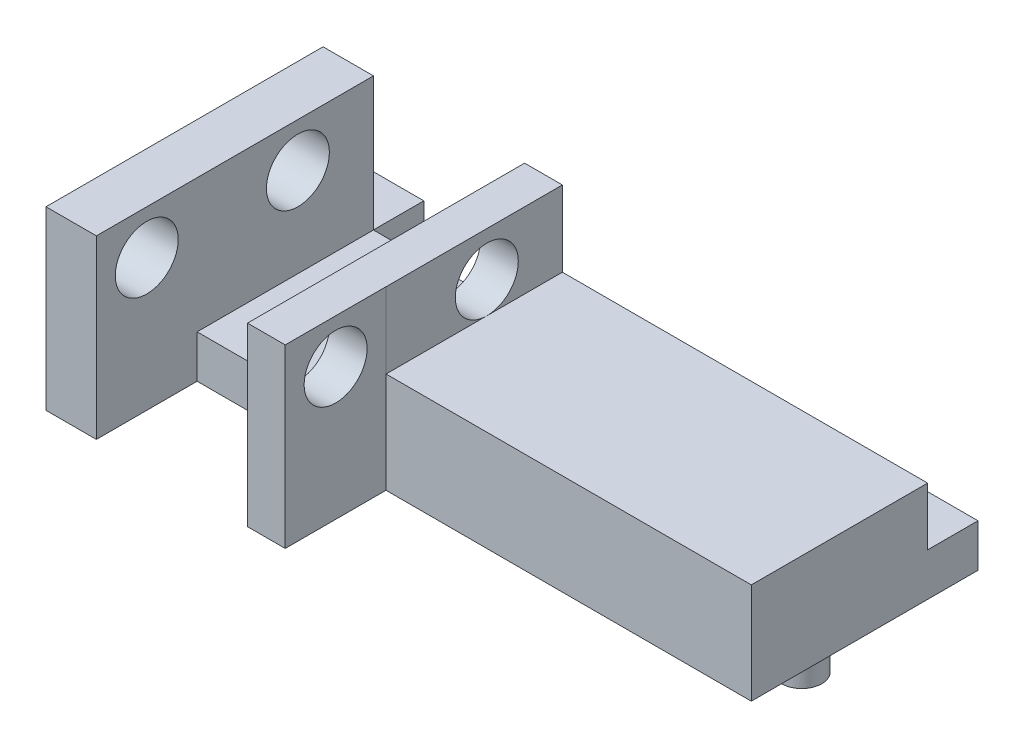
from build123d import *

# Parameters (mm, degrees)
BOSS_EXTRUDE1_DEPTH = 3
SKETCH3_W           = 24
SKETCH3_H           = 4
BOSS_EXTRUDE2_DEPTH = 4
SKETCH6_W           = 24
SKETCH6_H           = 4
BOSS_EXTRUDE4_DEPTH = 3
CUT_EXTRUDE1_DEPTH  = 2.3
SKETCH9_W           = 2
SKETCH9_H           = 7
SKETCH9_W_2         = 1.5
BOSS_EXTRUDE5_DEPTH = 3
SKETCH11_W          = 2
SKETCH11_H          = 7
SKETCH11_W_2        = 1.497470588
BOSS_EXTRUDE6_DEPTH = 4
SKETCH10_R          = 1.25
CUT_EXTRUDE2_DEPTH  = 10.5
BOSS_EXTRUDE7_DEPTH = 2


with BuildPart() as part:
    # Sketch1 → Boss-Extrude1 (new body)
    with BuildSketch(Plane(origin=(0, 0, 0), x_dir=(1, 0, 0), z_dir=(0, 1, 0))):
        with BuildLine():
            ThreePointArc((-17.3, 2), (-18.5, 3.2), (-19.7, 2))
            Line((-19.7, 2), (-17.3, 2))
        make_face()
        with BuildLine():
            Line((-17.3, 2), (-19.7, 2))
            ThreePointArc((-19.7, 2), (-18.5, 0.8), (-17.3, 2))
        make_face()
        with BuildLine():
            Line((-23, 2.8), (-23, 2))
            Line((-23, 2), (-23, 1.2))
            ThreePointArc((-23, 1.2), (-22.434314575, 1.434314575), (-22.2, 2))
            ThreePointArc((-22.2, 2), (-22.434314575, 2.565685425), (-23, 2.8))
        make_face()
        with BuildLine():
            Line((-23, 1.2), (-23, 2))
            Line((-23, 2), (-23.8, 2))
            ThreePointArc((-23.8, 2), (-23.565685425, 1.434314575), (-23, 1.2))
        make_face()
        with BuildLine():
            Line((-23.8, 2), (-23, 2))
            Line((-23, 2), (-23, 2.8))
            ThreePointArc((-23, 2.8), (-23.565685425, 2.565685425), (-23.8, 2))
        make_face()
        with BuildLine():
            ThreePointArc((-13.2, 2), (-14, 2.8), (-14.8, 2))
            Line((-14.8, 2), (-13.2, 2))
        make_face()
        with BuildLine():
            Line((-13.2, 2), (-14.8, 2))
            ThreePointArc((-14.8, 2), (-14, 1.2), (-13.2, 2))
        make_face()
        with BuildLine():
            ThreePointArc((-3.2, 2), (-4, 2.8), (-4.8, 2))
            Line((-4.8, 2), (-3.2, 2))
        make_face()
        with BuildLine():
            Line((-3.2, 2), (-4.8, 2))
            ThreePointArc((-4.8, 2), (-4, 1.2), (-3.2, 2))
        make_face()
    extrude(amount=-BOSS_EXTRUDE1_DEPTH)

    # Sketch3 → Boss-Extrude2 (add)
    with BuildSketch(Plane(origin=(0, 0, 0), x_dir=(1, 0, 0), z_dir=(0, 1, 0))):
        with Locations((-13, 2)):
            Rectangle(SKETCH3_W, SKETCH3_H)
    extrude(amount=BOSS_EXTRUDE2_DEPTH)

    # Sketch6 → Boss-Extrude4 (add)
    with BuildSketch(Plane.XY):
        with Locations((-13, 2)):
            Rectangle(SKETCH6_W, SKETCH6_H)
    extrude(amount=BOSS_EXTRUDE4_DEPTH)

    # Sketch7 → Cut-Extrude1 (cut)
    with BuildSketch(Plane(origin=(0, 4, 0), x_dir=(1, 0, 0), z_dir=(0, 1, 0))):
        Polygon((-23, 0.5), (-23, -3), (-17, -3), (-17, 4), (-23, 4), align=None)
    extrude(amount=-CUT_EXTRUDE1_DEPTH, mode=Mode.SUBTRACT)

    # Sketch9 → Boss-Extrude5 (add)
    with BuildSketch(Plane(origin=(0, 4, 0), x_dir=(1, 0, 0), z_dir=(0, 1, 0))):
        with Locations((-24, 0.5)):
            Rectangle(SKETCH9_W, SKETCH9_H)
        with Locations((-16.25, 0.5)):
            Rectangle(SKETCH9_W_2, SKETCH9_H)
    extrude(amount=BOSS_EXTRUDE5_DEPTH)

    # Sketch11 → Boss-Extrude6 (add)
    with BuildSketch(Plane.XY.offset(3)):
        with Locations((-24, 3.5)):
            Rectangle(SKETCH11_W, SKETCH11_H)
        with Locations((-16.251264706, 3.5)):
            Rectangle(SKETCH11_W_2, SKETCH11_H)
    extrude(amount=BOSS_EXTRUDE6_DEPTH)

    # Sketch10 → Cut-Extrude2 (cut, through all)
    with BuildSketch(Plane(origin=(-15.5, 0, 0), x_dir=(0, 0, -1), z_dir=(1, 0, 0))):
        with Locations((1, 5.25)):
            Circle(SKETCH10_R)
        with Locations((-5, 5.25)):
            Circle(SKETCH10_R)
    extrude(amount=-CUT_EXTRUDE2_DEPTH, mode=Mode.SUBTRACT)

    # Sketch12 → Boss-Extrude7 (add)
    with BuildSketch(Plane(origin=(0, 0, -4), x_dir=(-1, 0, 0), z_dir=(0, 0, -1))):
        Polygon((1, 0), (17, 0), (17, 1.7), (17, 1.704314434), (1, 1.704314434), align=None)
        Polygon((23, 0), (25, 0), (25, 1.704314434), (23, 1.704314434), (23, 1.7), align=None)
    extrude(amount=BOSS_EXTRUDE7_DEPTH)


solid = part.part
